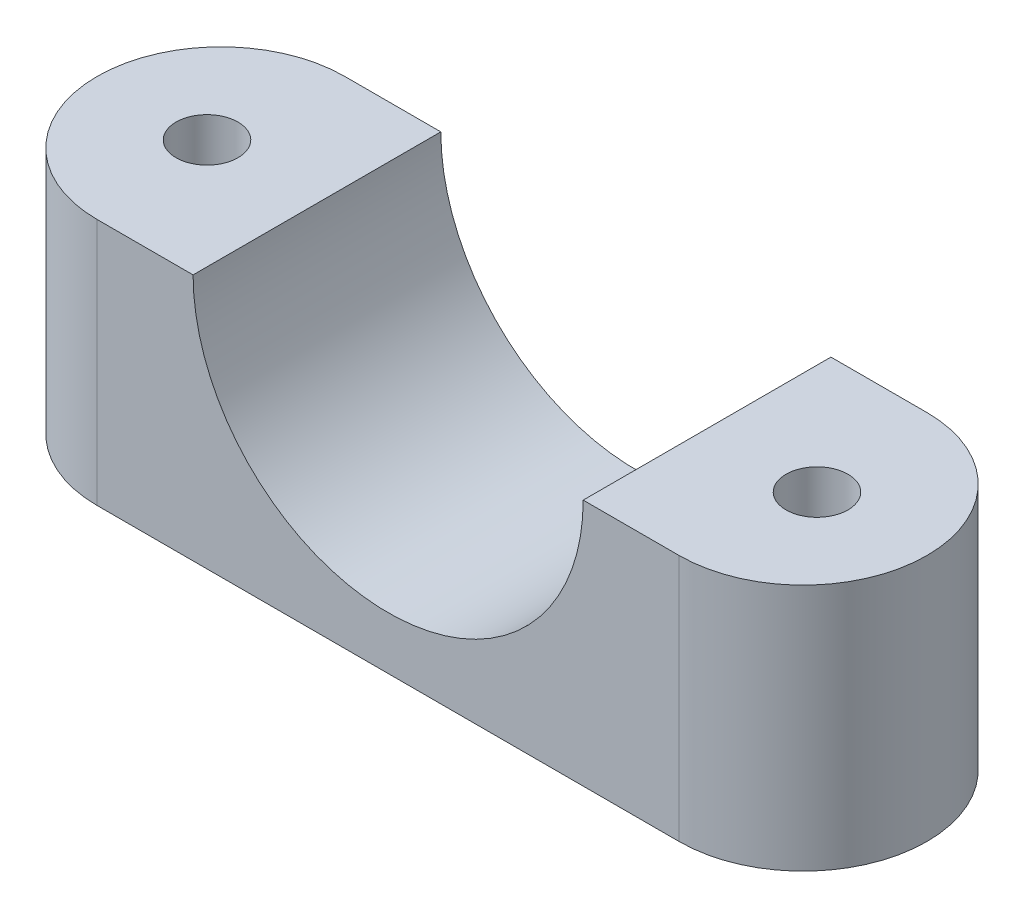
from build123d import *

# Parameters (mm, degrees)
BOSS_EXTRUDE1_DEPTH = 12.7
SKETCH2_R           = 3.175
CUT_EXTRUDE1_DEPTH  = 26.4
SKETCH3_OUTSIDE_W   = 105.562
SKETCH3_OUTSIDE_H   = 45.872
CUT_EXTRUDE4_DEPTH  = 25.4


with BuildPart() as part:
    # Sketch1 → Boss-Extrude1 (new body, symmetric)
    with BuildSketch(Plane.XY):
        with BuildLine():
            Line((-20, 0), (-42.545, 0))
            Line((-42.545, 0), (-42.545, -25.4))
            Line((-42.545, -25.4), (42.545, -25.4))
            Line((42.545, -25.4), (42.545, 0))
            Line((42.545, 0), (20, 0))
            ThreePointArc((20, 0), (0, -20), (-20, 0))
        make_face()
    extrude(amount=BOSS_EXTRUDE1_DEPTH, both=True)

    # Sketch2 → Cut-Extrude1 (cut, through all)
    with BuildSketch(Plane(origin=(0, 0, 0), x_dir=(1, 0, 0), z_dir=(0, 1, 0))):
        with Locations((-31.2725, 0)):
            Circle(SKETCH2_R)
    cut_extrude1 = extrude(amount=-CUT_EXTRUDE1_DEPTH, mode=Mode.SUBTRACT)

    # Mirror1: Cut-Extrude1 across plane
    add(cut_extrude1.mirror(Plane(origin=(0, 0, 0), x_dir=(0, 0, 1), z_dir=(1, 0, 0))), mode=Mode.SUBTRACT)

    # Sketch3 outside → Cut-Extrude4 (cut)
    with BuildSketch(Plane.XZ.offset(25.4)):
        Rectangle(SKETCH3_OUTSIDE_W, SKETCH3_OUTSIDE_H)
        with BuildLine():
            Line((-29.845, 12.7), (29.845, 12.7))
            ThreePointArc((29.845, 12.7), (42.545, 0), (29.845, -12.7))
            Line((29.845, -12.7), (-29.845, -12.7))
            ThreePointArc((-29.845, -12.7), (-42.545, 0), (-29.845, 12.7))
        make_face(mode=Mode.SUBTRACT)
    extrude(amount=-CUT_EXTRUDE4_DEPTH, mode=Mode.SUBTRACT)


solid = part.part
